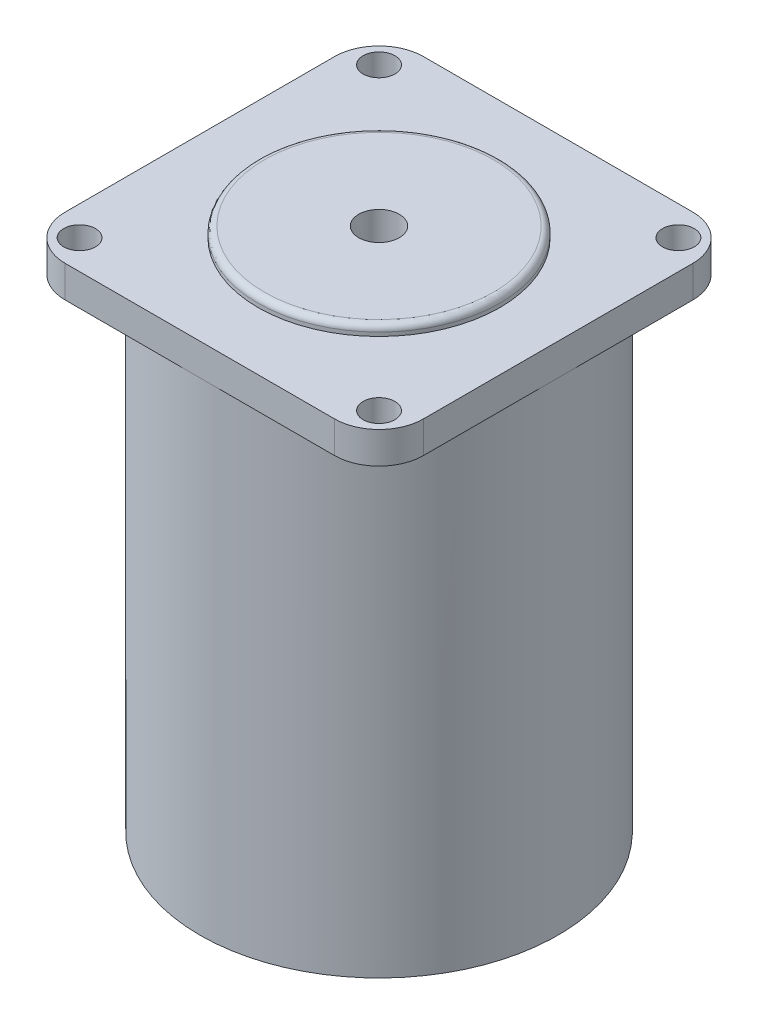
from build123d import *

# Parameters (mm, degrees)
SKETCH1_R           = 28.2
BOSS_EXTRUDE1_DEPTH = 76
BOSS_EXTRUDE3_DEPTH = 5
SKETCH4_R           = 2.5
CUT_EXTRUDE1_DEPTH  = 5
SKETCH5_R           = 19.05
BOSS_EXTRUDE4_DEPTH = 1.6
FILLET1_R           = 1
SKETCH7_R           = 3.2
CUT_EXTRUDE3_DEPTH  = 83.6


with BuildPart() as part:
    # Sketch1 → Boss-Extrude1 (new body)
    with BuildSketch(Plane(origin=(0, 0, 0), x_dir=(1, 0, 0), z_dir=(0, 1, 0))):
        Circle(SKETCH1_R)
    extrude(amount=BOSS_EXTRUDE1_DEPTH)

    # Sketch2 → Boss-Extrude3 (add)
    with BuildSketch(Plane(origin=(0, 76, 0), x_dir=(1, 0, 0), z_dir=(0, 1, 0))):
        with BuildLine():
            Line((-21.2, -28.2), (21.2, -28.2))
            ThreePointArc((21.2, -28.2), (26.149747468, -26.149747468), (28.2, -21.2))
            Line((28.2, -21.2), (28.2, 21.2))
            ThreePointArc((28.2, 21.2), (26.149747468, 26.149747468), (21.2, 28.2))
            Line((21.2, 28.2), (-21.2, 28.2))
            ThreePointArc((-21.2, 28.2), (-26.149747468, 26.149747468), (-28.2, 21.2))
            Line((-28.2, 21.2), (-28.2, -21.2))
            ThreePointArc((-28.2, -21.2), (-26.149747468, -26.149747468), (-21.2, -28.2))
        make_face()
    extrude(amount=BOSS_EXTRUDE3_DEPTH)

    # Sketch4 → Cut-Extrude1 (cut)
    with BuildSketch(Plane(origin=(0, 81, 0), x_dir=(1, 0, 0), z_dir=(0, 1, 0))):
        with Locations((-23.57, 23.57)):
            Circle(SKETCH4_R)
        with Locations((23.57, 23.57)):
            Circle(SKETCH4_R)
        with Locations((-23.57, -23.57)):
            Circle(SKETCH4_R)
        with Locations((23.57, -23.57)):
            Circle(SKETCH4_R)
    extrude(amount=-CUT_EXTRUDE1_DEPTH, mode=Mode.SUBTRACT)

    # Sketch5 → Boss-Extrude4 (add)
    with BuildSketch(Plane(origin=(0, 81, 0), x_dir=(1, 0, 0), z_dir=(0, 1, 0))):
        Circle(SKETCH5_R)
    extrude(amount=BOSS_EXTRUDE4_DEPTH)

    # Fillet1
    fillet1_edges = [part.edges().sort_by_distance(p)[0] for p in [
        (-19.05, 82.6, 0),
    ]]
    fillet(fillet1_edges, radius=FILLET1_R)

    # Sketch7 → Cut-Extrude3 (cut, through all)
    with BuildSketch(Plane(origin=(0, 82.6, 0), x_dir=(1, 0, 0), z_dir=(0, 1, 0))):
        Circle(SKETCH7_R)
    extrude(amount=-CUT_EXTRUDE3_DEPTH, mode=Mode.SUBTRACT)


solid = part.part
